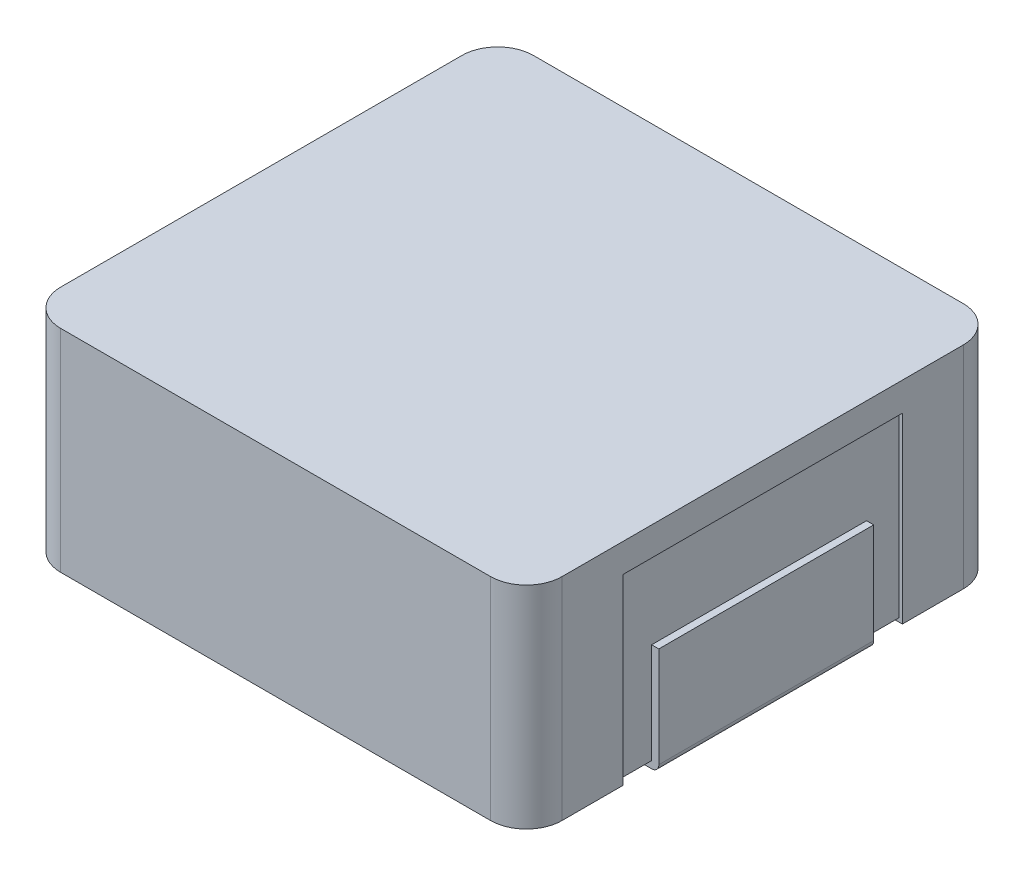
from build123d import *

# Parameters (mm, degrees)
EXTRUDE_1_DEPTH     = 2.95
SKETCH_2_W          = 2.55
SKETCH_2_H          = 3.9
CUT_EXTRUDE_1_DEPTH = 0.05
SKETCH_6_W          = 3.9
SKETCH_6_H          = 2.55
CUT_EXTRUDE_3_DEPTH = 0.05
EXTRUDE_3_DEPTH     = 3


with BuildPart() as part:
    # 草图1 → 凸台-拉伸1 (new body)
    with BuildSketch(Plane(origin=(0, 0, 0), x_dir=(1, 0, 0), z_dir=(0, 1, 0))):
        with BuildLine():
            Line((-3, -3.3), (3, -3.3))
            ThreePointArc((3, -3.3), (3.353553391, -3.153553391), (3.5, -2.8))
            Line((3.5, -2.8), (3.5, 2.8))
            ThreePointArc((3.5, 2.8), (3.353553391, 3.153553391), (3, 3.3))
            Line((3, 3.3), (-3, 3.3))
            ThreePointArc((-3, 3.3), (-3.353553391, 3.153553391), (-3.5, 2.8))
            Line((-3.5, 2.8), (-3.5, -2.8))
            ThreePointArc((-3.5, -2.8), (-3.353553391, -3.153553391), (-3, -3.3))
        make_face()
    extrude(amount=EXTRUDE_1_DEPTH)

    # 草图2 → 切除-拉伸1 (cut)
    with BuildSketch(Plane.XZ):
        with Locations((-2.225, 0)):
            Rectangle(SKETCH_2_W, SKETCH_2_H)
        with Locations((2.225, 0)):
            Rectangle(SKETCH_2_W, SKETCH_2_H)
    extrude(amount=-CUT_EXTRUDE_1_DEPTH, mode=Mode.SUBTRACT)

    # 草图6 → 切除-拉伸3 (cut)
    with BuildSketch(Plane.ZY.offset(3.5)):
        with Locations((0, 1.275)):
            Rectangle(SKETCH_6_W, SKETCH_6_H)
    cut_extrude_3 = extrude(amount=-CUT_EXTRUDE_3_DEPTH, mode=Mode.SUBTRACT)

    # 镜向3: 切除-拉伸3 across plane
    add(cut_extrude_3.mirror(Plane.ZY), mode=Mode.SUBTRACT)


with BuildPart() as body_2:
    # 草图8 → 凸台-拉伸3 (new body)
    with BuildSketch(Plane(origin=(0, 0, -1.5), x_dir=(-1, 0, 0), z_dir=(0, 0, -1))):
        with BuildLine():
            Line((2.05, 0.05), (2.05, -0.05))
            Line((2.05, -0.05), (3.45, -0.05))
            ThreePointArc((3.45, -0.05), (3.520710678, -0.020710678), (3.55, 0.05))
            Line((3.55, 0.05), (3.55, 1.45))
            Line((3.55, 1.45), (3.45, 1.45))
            Line((3.45, 1.45), (3.45, 0.05))
            Line((3.45, 0.05), (2.05, 0.05))
        make_face()
    extrude_3 = extrude(amount=-EXTRUDE_3_DEPTH)


with BuildPart() as part_1:
    add(part.part)

    # 镜向4: 凸台-拉伸3 across plane
    add(extrude_3.mirror(Plane.ZY))


solid = Compound([body_2.part, part_1.part])
